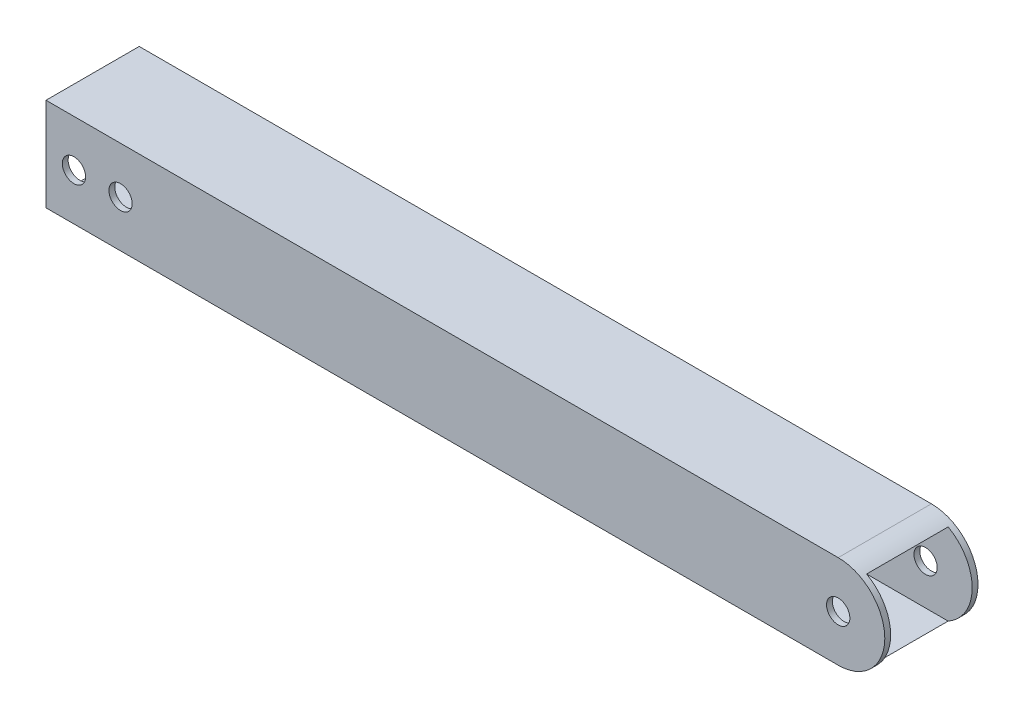
from build123d import *

# Parameters (mm, degrees)
SKETCH1_W           = 25.4
SKETCH1_H           = 25.4
SKETCH1_W_2         = 22.225
SKETCH1_H_2         = 22.225
BOSS_EXTRUDE1_DEPTH = 228.6
SKETCH2_R           = 3.175
CUT_EXTRUDE1_DEPTH  = 26.4
CUT_EXTRUDE2_DEPTH  = 26.4


with BuildPart() as part:
    # Sketch1 → Boss-Extrude1 (new body)
    with BuildSketch(Plane(origin=(0, 0, 0), x_dir=(0, 0, -1), z_dir=(1, 0, 0))):
        Rectangle(SKETCH1_W, SKETCH1_H)
        Rectangle(SKETCH1_W_2, SKETCH1_H_2, mode=Mode.SUBTRACT)
    extrude(amount=BOSS_EXTRUDE1_DEPTH)

    # Sketch2 → Cut-Extrude1 (cut, through all)
    with BuildSketch(Plane.XY.offset(12.7)):
        with Locations((215.9, 0)):
            Circle(SKETCH2_R)
        with Locations((7.62, 0)):
            Circle(SKETCH2_R)
        with Locations((20.32, 0)):
            Circle(SKETCH2_R)
    extrude(amount=-CUT_EXTRUDE1_DEPTH, mode=Mode.SUBTRACT)

    # Sketch3 → Cut-Extrude2 (cut, through all)
    with BuildSketch(Plane.XY.offset(12.7)):
        with BuildLine():
            Line((228.6, 12.7), (215.9, 12.7))
            ThreePointArc((215.9, 12.7), (224.880256121, 8.980256121), (228.6, 0))
            Line((228.6, 0), (228.6, 12.7))
        make_face()
        with BuildLine():
            Line((228.6, -12.7), (228.6, 0))
            ThreePointArc((228.6, 0), (224.880256121, -8.980256121), (215.9, -12.7))
            Line((215.9, -12.7), (228.6, -12.7))
        make_face()
    extrude(amount=-CUT_EXTRUDE2_DEPTH, mode=Mode.SUBTRACT)


solid = part.part
